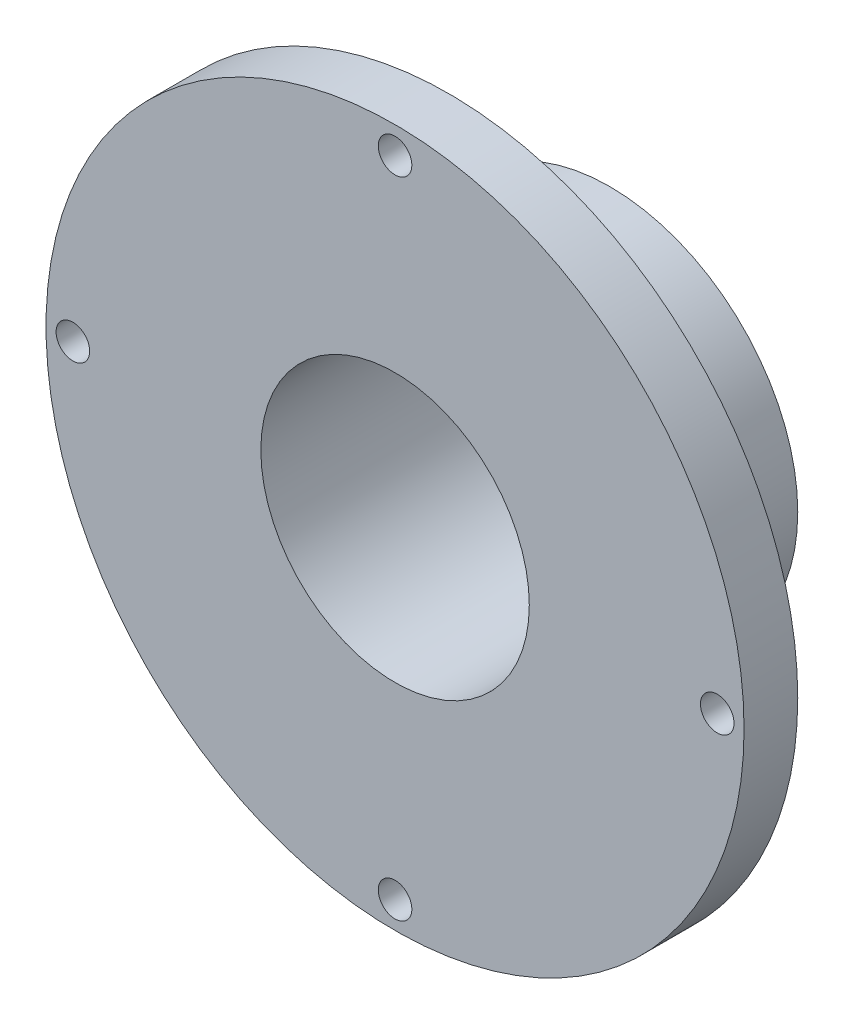
from build123d import *

# Parameters (mm, degrees)
SKETCH1_R                       = 41.275
BOSS_EXTRUDE1_DEPTH             = 25.4
SKETCH2_OUTSIDE_W               = 108.444
SKETCH2_OUTSIDE_H               = 108.444
SKETCH2_OUTSIDE_R               = 22.225
CUT_EXTRUDE1_DEPTH              = 19.05
SKETCH3_R                       = 15.875
CUT_EXTRUDE2_DEPTH              = 26.4
F_4_40_TAPPED_HOLE1_D           = 2.2606
F_4_40_TAPPED_HOLE1_DEPTH       = 7.5946
F_4_40_TAPPED_HOLE1_TIP         = 0.679152758
F_5_32_0_15625_DIAMETER_HOLE1_D = 3.96875
MIRROR2_COPY_1_D                = 3.96875
MIRROR2_COPY_2_D                = 3.96875


with BuildPart() as part:
    # Sketch1 → Boss-Extrude1 (new body)
    with BuildSketch(Plane.XY):
        Circle(SKETCH1_R)
    extrude(amount=BOSS_EXTRUDE1_DEPTH)

    # Sketch2 outside → Cut-Extrude1 (cut)
    with BuildSketch(Plane(origin=(0, 0, 0), x_dir=(-1, 0, 0), z_dir=(0, 0, -1))):
        Rectangle(SKETCH2_OUTSIDE_W, SKETCH2_OUTSIDE_H)
        Circle(SKETCH2_OUTSIDE_R, mode=Mode.SUBTRACT)
    extrude(amount=-CUT_EXTRUDE1_DEPTH, mode=Mode.SUBTRACT)

    # Sketch3 → Cut-Extrude2 (cut, through all)
    with BuildSketch(Plane(origin=(0, 0, 0), x_dir=(-1, 0, 0), z_dir=(0, 0, -1))):
        Circle(SKETCH3_R)
    extrude(amount=-CUT_EXTRUDE2_DEPTH, mode=Mode.SUBTRACT)

    # #4-40 Tapped Hole1
    with Locations(Plane(origin=(0, 0, 0), x_dir=(-1, 0, 0), z_dir=(0, 0, -1))):
        with Locations((0, 18.415), (0, -18.415)):
            Hole(F_4_40_TAPPED_HOLE1_D / 2, depth=F_4_40_TAPPED_HOLE1_DEPTH)
            with Locations((0, 0, -(F_4_40_TAPPED_HOLE1_DEPTH + F_4_40_TAPPED_HOLE1_TIP / 2))):  # 118° drill point
                Cone(0, F_4_40_TAPPED_HOLE1_D / 2, F_4_40_TAPPED_HOLE1_TIP, mode=Mode.SUBTRACT)

    # 5/32 (0.15625) Diameter Hole1 (through all)
    with Locations(Plane.XY.offset(25.4)):
        with Locations((0, 38.1), (38.1, 0)):
            f_5_32_0_15625_diameter_hole1 = Hole(F_5_32_0_15625_DIAMETER_HOLE1_D / 2)

    # Mirror1: 5/32 (0.15625) Diameter Hole1 across plane
    add(f_5_32_0_15625_diameter_hole1.mirror(Plane.ZX), mode=Mode.SUBTRACT)

    # Mirror2 copy 1 (through all)
    with Locations(Plane(origin=(0, 0, 25.4), x_dir=(-1, 0, 0), z_dir=(0, 0, 1))):
        with Locations((0, 38.1), (38.1, 0)):
            Hole(MIRROR2_COPY_1_D / 2)

    # Mirror2 copy 2 (through all)
    with Locations(Plane(origin=(0, 0, 25.4), x_dir=(-1, 0, 0), z_dir=(0, 0, 1))):
        with Locations((0, -38.1), (38.1, 0)):
            Hole(MIRROR2_COPY_2_D / 2)


solid = part.part
